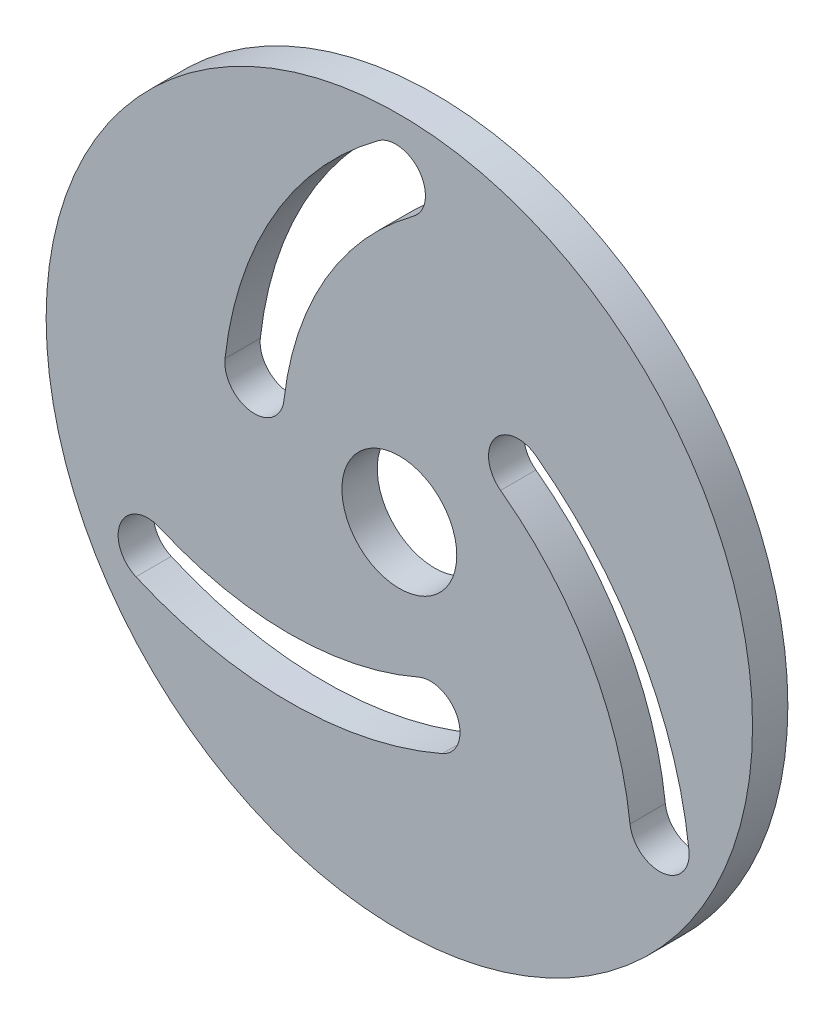
from build123d import *

# Parameters (mm, degrees)
SKETCH1_R           = 25
SKETCH1_R_2         = 4.064
BOSS_EXTRUDE1_DEPTH = 2.5


with BuildPart() as part:
    # Sketch1 → Boss-Extrude1 (new body)
    with BuildSketch(Plane.XY):
        with Locations((-21.594590832, 6.574444403)):
            Circle(SKETCH1_R)
        with Locations((-21.594590832, 6.574444403)):
            Circle(SKETCH1_R_2, mode=Mode.SUBTRACT)
        with BuildLine():
            ThreePointArc((-1.094322082, -3.289024862), (-4.554991799, 7.229910381), (-11.934322082, 15.486405892))
            ThreePointArc((-11.934322082, 15.486405892), (-14.870947643, 15.043426983), (-14.427968734, 12.106801422))
            ThreePointArc((-14.427968734, 12.106801422), (-8.192298494, 5.129910381), (-5.267968734, -3.758783976))
            ThreePointArc((-5.267968734, -3.758783976), (-2.946265851, -5.610727745), (-1.094322082, -3.289024862))
        make_face(mode=Mode.SUBTRACT)
        with BuildLine():
            ThreePointArc((-40.23766089, -6.093180307), (-29.39766089, -8.35562004), (-18.55766089, -6.093180307))
            ThreePointArc((-18.55766089, -6.093180307), (-17.472979098, -3.328498515), (-20.23766089, -2.243816723))
            ThreePointArc((-20.23766089, -2.243816723), (-29.39766089, -4.15562004), (-38.55766089, -2.243816723))
            ThreePointArc((-38.55766089, -2.243816723), (-41.322342681, -3.328498515), (-40.23766089, -6.093180307))
        make_face(mode=Mode.SUBTRACT)
        with BuildLine():
            ThreePointArc((-33.934461337, 10.432592457), (-32.082517568, 8.110889575), (-29.760814685, 9.962833344))
            ThreePointArc((-29.760814685, 9.962833344), (-26.836484925, 18.851527701), (-20.600814685, 25.828418741))
            ThreePointArc((-20.600814685, 25.828418741), (-20.157835776, 28.765044302), (-23.094461337, 29.208023212))
            ThreePointArc((-23.094461337, 29.208023212), (-30.473791621, 20.951527701), (-33.934461337, 10.432592457))
        make_face(mode=Mode.SUBTRACT)
    extrude(amount=BOSS_EXTRUDE1_DEPTH)


solid = part.part
